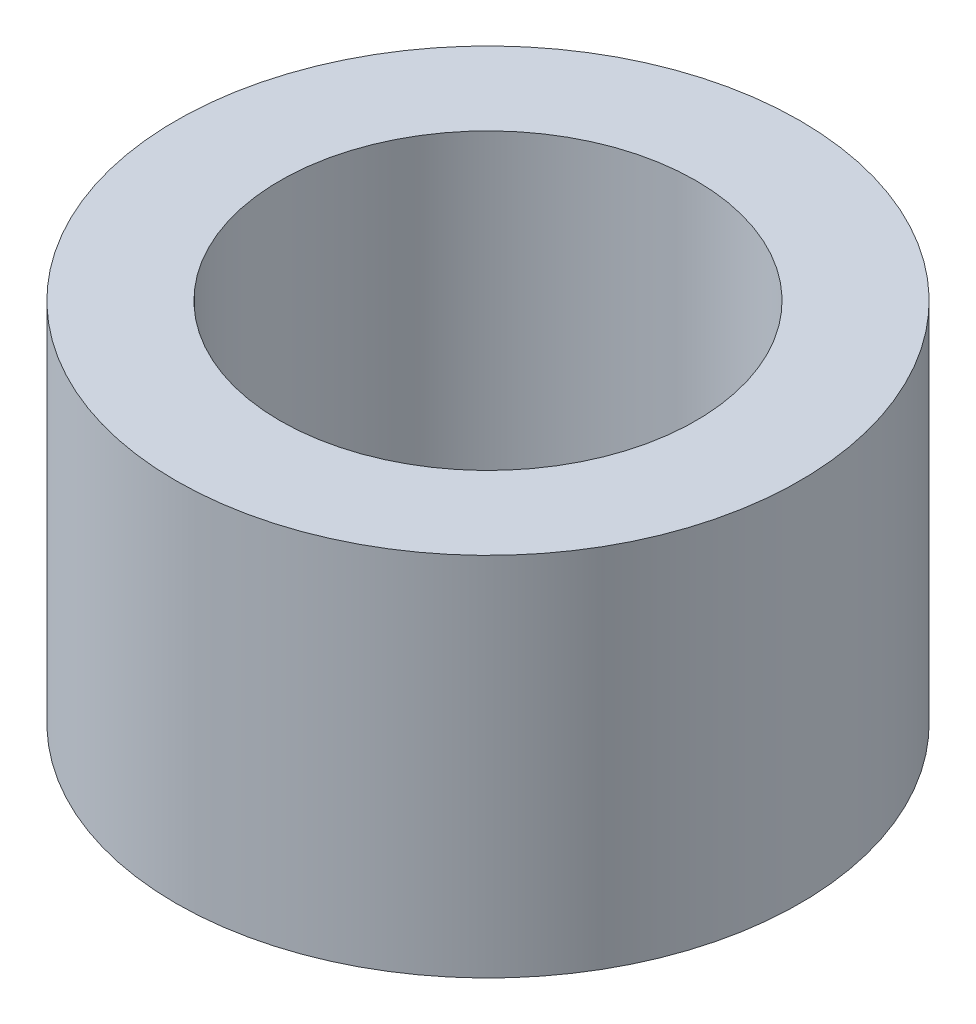
from build123d import *

# Parameters (mm, degrees)
SKETCH1_R           = 9.525
SKETCH1_R_2         = 6.35
BOSS_EXTRUDE1_DEPTH = 11.176


with BuildPart() as part:
    # Sketch1 → Boss-Extrude1 (new body)
    with BuildSketch(Plane(origin=(0, 0, 0), x_dir=(1, 0, 0), z_dir=(0, 1, 0))):
        Circle(SKETCH1_R)
        Circle(SKETCH1_R_2, mode=Mode.SUBTRACT)
    extrude(amount=BOSS_EXTRUDE1_DEPTH)


solid = part.part
